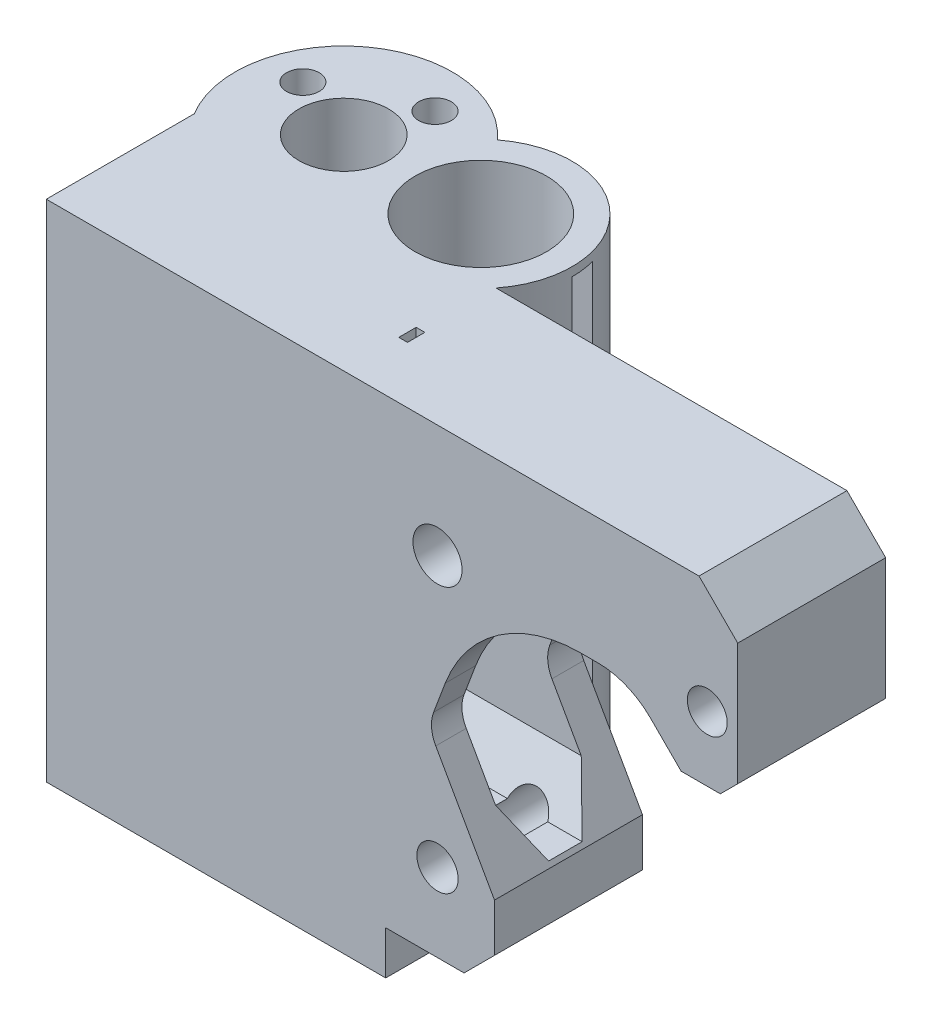
from build123d import *

# Parameters (mm, degrees)
BOSS_EXTRUDE1_DEPTH     = 17
SKETCH2_R               = 10.5
BOSS_EXTRUDE2_DEPTH     = 58
SKETCH3_R               = 12.5
BOSS_EXTRUDE3_DEPTH     = 13.5
SKETCH4_R               = 7.55
SKETCH4_R_2             = 5.15
CUT_EXTRUDE1_DEPTH      = 59
SKETCH5_R               = 4.05
CUT_EXTRUDE2_DEPTH      = 35
SKETCH6_R               = 2.293291756
SKETCH6_R_2             = 2.82251293
SKETCH6_R_3             = 2.373314239
CUT_EXTRUDE3_DEPTH      = 18
CUT_EXTRUDE4_DEPTH      = 20
SKETCH10_R              = 1.875
CUT_EXTRUDE6_DEPTH      = 59
SKETCH11_W              = 1
SKETCH11_H              = 2
CUT_EXTRUDE7_DEPTH      = 8
CUT_EXTRUDE9_DEPTH      = 1
CUT_EXTRUDE9_DEPTH_BACK = 57


with BuildPart() as part:
    # Sketch1 → Boss-Extrude1 (new body)
    with BuildSketch(Plane.XY):
        with BuildLine():
            Line((39, -53), (48, -53))
            Line((48, -53), (51.5, -49.5))
            Line((51.5, -49.5), (51.5, -44))
            Line((51.5, -44), (44.75, -32.029420251))
            ThreePointArc((44.75, -32.029420251), (44.267998826, -30.444746543), (44.500869457, -28.804841922))
            Line((44.500869457, -28.804841922), (45.840453499, -25.237554933))
            ThreePointArc((45.840453499, -25.237554933), (51.941858088, -17.410271227), (61.414466094, -14.45))
            Line((61.414466094, -14.45), (63.414466094, -14.45))
            ThreePointArc((63.414466094, -14.45), (66.680873506, -15.099728831), (69.45, -16.95))
            Line((69.45, -16.95), (72.95, -20.45))
            Line((72.95, -20.45), (77.45, -20.45))
            Line((77.45, -20.45), (79.45, -18.45))
            Line((79.45, -18.45), (79.45, -4.45))
            Line((79.45, -4.45), (75, 0))
            Line((75, 0), (39, 0))
            Line((39, 0), (0, 0))
            Line((0, 0), (0, -58))
            Line((0, -58), (39, -58))
            Line((39, -58), (39, -53))
        make_face()
    extrude(amount=BOSS_EXTRUDE1_DEPTH)

    # Sketch2 → Boss-Extrude2 (add)
    with BuildSketch(Plane(origin=(0, 0, 0), x_dir=(1, 0, 0), z_dir=(0, 1, 0))):
        with Locations((26.427, 6.5)):
            Circle(SKETCH2_R)
    extrude(amount=-BOSS_EXTRUDE2_DEPTH)

    # Sketch3 → Boss-Extrude3 (add)
    with BuildSketch(Plane(origin=(0, 0, 0), x_dir=(1, 0, 0), z_dir=(0, 1, 0))):
        with Locations((10.677078252, 6.5)):
            Circle(SKETCH3_R)
    extrude(amount=-BOSS_EXTRUDE3_DEPTH)

    # Sketch4 → Cut-Extrude1 (cut, through all)
    with BuildSketch(Plane(origin=(0, 0, 0), x_dir=(1, 0, 0), z_dir=(0, 1, 0))):
        with Locations((26.427, 6.5)):
            Circle(SKETCH4_R)
        with Locations((10.677078252, 6.5)):
            Circle(SKETCH4_R_2)
    extrude(amount=-CUT_EXTRUDE1_DEPTH, mode=Mode.SUBTRACT)

    # Sketch5 → Cut-Extrude2 (cut)
    with BuildSketch(Plane.ZY):
        with Locations((8.5, -6)):
            Circle(SKETCH5_R)
        with Locations((8.5, -51)):
            Circle(SKETCH5_R)
        Polygon((10.5, -43.5), (6.65, -43.5), (3.65, -38), (3.65, -19), (6.65, -13.5), (10.5, -13.5), (13.5, -19), (13.5, -38), align=None)
    extrude(amount=-CUT_EXTRUDE2_DEPTH, mode=Mode.SUBTRACT)

    # Sketch6 → Cut-Extrude3 (cut, through all)
    with BuildSketch(Plane(origin=(0, 0, 0), x_dir=(-1, 0, 0), z_dir=(0, 0, -1))):
        with Locations((-75.950256659, -13)):
            Circle(SKETCH6_R)
        with Locations((-44.950256659, -13)):
            Circle(SKETCH6_R_2)
        with Locations((-44.950256659, -44)):
            Circle(SKETCH6_R_3)
    extrude(amount=-CUT_EXTRUDE3_DEPTH, mode=Mode.SUBTRACT)

    # Sketch8 → Cut-Extrude4 (cut)
    with BuildSketch(Plane.ZY.offset(-35)):
        Polygon((10.5, -43.5), (13.5, -38), (13.5, -19), (10.5, -13.5), (6.65, -13.5), (3.65, -19), (3.65, -38), (6.65, -43.5), align=None)
    extrude(amount=-CUT_EXTRUDE4_DEPTH, mode=Mode.SUBTRACT)

    # Sketch10 → Cut-Extrude6 (cut, through all)
    with BuildSketch(Plane(origin=(0, 0, 0), x_dir=(1, 0, 0), z_dir=(0, 1, 0))):
        with Locations((13.570159095, 14.092477082)):
            Circle(SKETCH10_R)
        with Locations((3.08460117, 9.393080843)):
            Circle(SKETCH10_R)
    extrude(amount=-CUT_EXTRUDE6_DEPTH, mode=Mode.SUBTRACT)

    # Sketch11 → Cut-Extrude7 (cut)
    with BuildSketch(Plane.XZ.offset(58)):
        with Locations((34.5, 9.5)):
            Rectangle(SKETCH11_W, SKETCH11_H)
    cut_extrude7 = extrude(amount=-CUT_EXTRUDE7_DEPTH, mode=Mode.SUBTRACT)

    # Mirror1: Cut-Extrude7 across plane
    add(cut_extrude7.mirror(Plane.ZX.offset(-29)), mode=Mode.SUBTRACT)

    # Sketch13 → Cut-Extrude9 (cut, two sides)
    with BuildSketch(Plane.XZ.offset(58)) as cut_extrude9_sk:
        with BuildLine():
            Line((147.448117004, -6.5), (36.927, -6.5))
            Line((36.927, -6.5), (33.977, -6.5))
            ThreePointArc((33.977, -6.5), (33.912408703, -7.485472751), (33.719739988, -8.454083791))
            Line((33.719739988, -8.454083791), (36.569221176, -9.217599974))
            Line((36.569221176, -9.217599974), (143.32442244, -37.82256994))
            Line((143.32442244, -37.82256994), (362.475609494, -66.674371065))
            Line((362.475609494, -66.674371065), (366.599304057, -35.351801125))
            Line((366.599304057, -35.351801125), (147.448117004, -6.5))
        make_face()
    extrude(amount=CUT_EXTRUDE9_DEPTH, mode=Mode.SUBTRACT)
    extrude(cut_extrude9_sk.sketch, amount=-CUT_EXTRUDE9_DEPTH_BACK, mode=Mode.SUBTRACT)


solid = part.part
